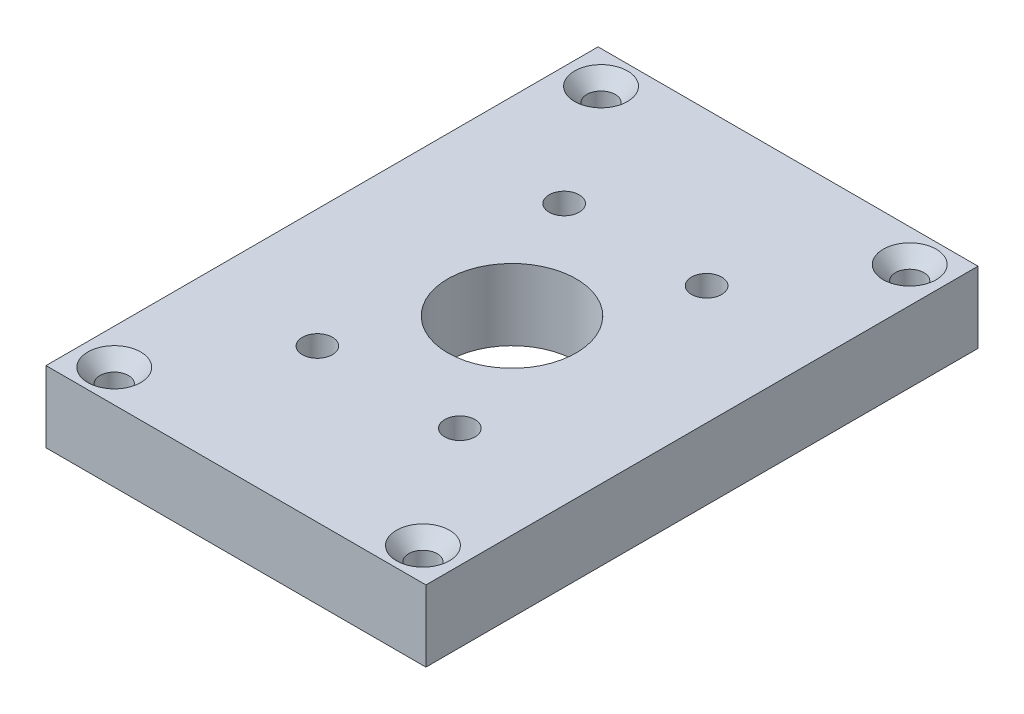
from build123d import *

# Parameters (mm, degrees)
SKETCH1_W                                      = 50.8
SKETCH1_H                                      = 73.81875
BOSS_EXTRUDE1_DEPTH                            = 9.525
CSK_FOR_6_FLAT_HEAD_MACHINE_SCREW1_D           = 3.7973
CSK_FOR_6_FLAT_HEAD_MACHINE_SCREW1_CSINK_D     = 7.0866
CSK_FOR_6_FLAT_HEAD_MACHINE_SCREW1_CSINK_ANGLE = 82
CUT_EXTRUDE1_DASH_036_DEPTH                    = 1.3208
SKETCH5_R                                      = 8.5852
CUT_EXTRUDE1_DEPTH                             = 10.525
CIRPATTERN1_COUNT                              = 6


with BuildPart() as part:
    # Sketch1 → Boss-Extrude1 (new body)
    with BuildSketch(Plane(origin=(0, 0, 0), x_dir=(1, 0, 0), z_dir=(0, 1, 0))):
        Rectangle(SKETCH1_W, SKETCH1_H)
    extrude(amount=BOSS_EXTRUDE1_DEPTH)

    # CSK for #6 Flat Head Machine Screw1 (through all)
    with Locations(Plane(origin=(0, 9.525, 0), x_dir=(-1, 0, 0), z_dir=(0, 1, 0))):
        with Locations((20.6375, -32.54375), (-20.6375, -32.54375), (-20.6375, 32.54375), (20.6375, 32.54375)):
            CounterSinkHole(CSK_FOR_6_FLAT_HEAD_MACHINE_SCREW1_D / 2, CSK_FOR_6_FLAT_HEAD_MACHINE_SCREW1_CSINK_D / 2, counter_sink_angle=CSK_FOR_6_FLAT_HEAD_MACHINE_SCREW1_CSINK_ANGLE)

    # Sketch4 → Cut-Extrude1 - dash 036 (cut)
    with BuildSketch(Plane(origin=(0, 0, 0), x_dir=(-1, 0, 0), z_dir=(0, -1, 0))):
        with BuildLine():
            Line((-11.1125, 34.6075), (11.1125, 34.6075))
            ThreePointArc((11.1125, 34.6075), (17.147232113, 32.107832113), (19.6469, 26.0731))
            Line((19.6469, 26.0731), (19.6469, -26.0731))
            ThreePointArc((19.6469, -26.0731), (17.147232113, -32.107832113), (11.1125, -34.6075))
            Line((11.1125, -34.6075), (-11.1125, -34.6075))
            ThreePointArc((-11.1125, -34.6075), (-17.147232113, -32.107832113), (-19.6469, -26.0731))
            Line((-19.6469, -26.0731), (-19.6469, 26.0731))
            ThreePointArc((-19.6469, 26.0731), (-17.147232113, 32.107832113), (-11.1125, 34.6075))
        make_face()
        with BuildLine():
            Line((-11.1125, -32.4231), (11.1125, -32.4231))
            ThreePointArc((11.1125, -32.4231), (15.602628061, -30.563228061), (17.4625, -26.0731))
            Line((17.4625, -26.0731), (17.4625, 26.0731))
            ThreePointArc((17.4625, 26.0731), (15.602628061, 30.563228061), (11.1125, 32.4231))
            Line((11.1125, 32.4231), (-11.1125, 32.4231))
            ThreePointArc((-11.1125, 32.4231), (-15.602628061, 30.563228061), (-17.4625, 26.0731))
            Line((-17.4625, 26.0731), (-17.4625, -26.0731))
            ThreePointArc((-17.4625, -26.0731), (-15.602628061, -30.563228061), (-11.1125, -32.4231))
        make_face(mode=Mode.SUBTRACT)
    extrude(amount=-CUT_EXTRUDE1_DASH_036_DEPTH, mode=Mode.SUBTRACT)

    # Sketch5 → Cut-Extrude1 (cut, through all)
    with BuildSketch(Plane(origin=(0, 9.525, 0), x_dir=(1, 0, 0), z_dir=(0, 1, 0))):
        Circle(SKETCH5_R)
    extrude(amount=-CUT_EXTRUDE1_DEPTH, mode=Mode.SUBTRACT)

    # Sketch9 → #10-32 Tapped Hole2 (revolve, cut)
    with BuildSketch(Plane(origin=(9.525, 9.525, -16.497783942), x_dir=(0, 0, 1), z_dir=(1, 0, 0))):
        Polygon((0, 0), (0, 7.563317848), (2.0193, 6.35), (2.0193, 0), align=None)
    f_10_32_tapped_hole2 = revolve(axis=Axis((9.525, 15.875, -16.497783942), (0, -1, 0)), mode=Mode.SUBTRACT)

    # CirPattern1: #10-32 Tapped Hole2 ×6 about axis, 2 skipped
    cirpattern1_axis = Axis((0, 0, 0), (0, 1, 0))
    add([f_10_32_tapped_hole2.rotate(cirpattern1_axis, i * 360 / CIRPATTERN1_COUNT) for i in range(1, CIRPATTERN1_COUNT) if i not in (2, 5)], mode=Mode.SUBTRACT)


solid = part.part
